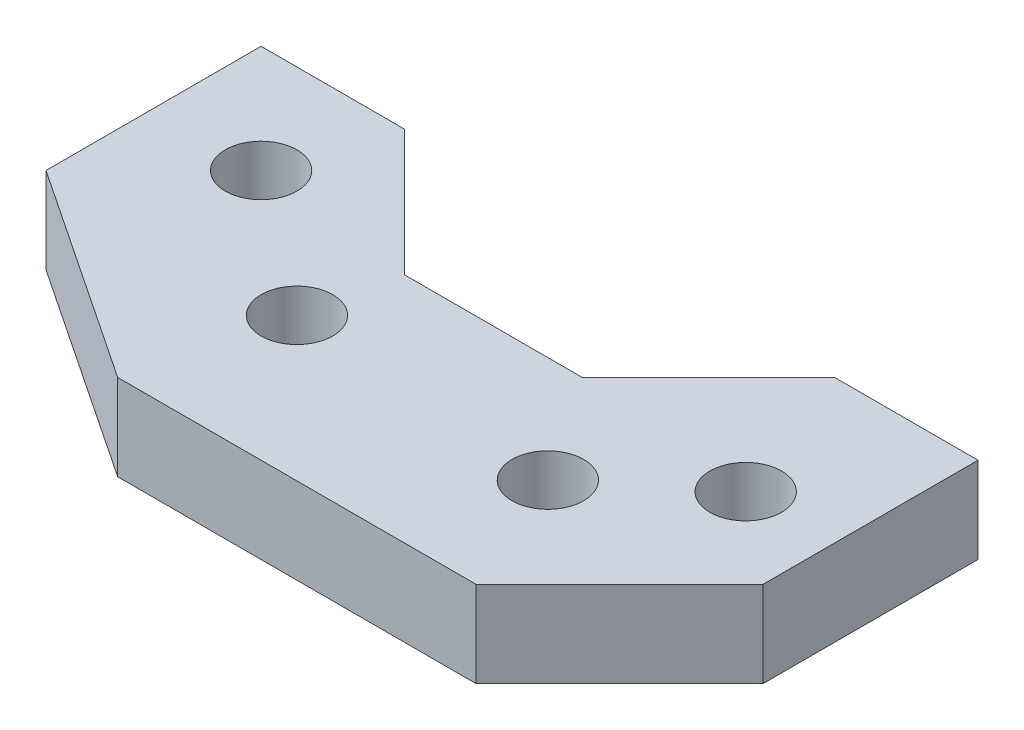
from build123d import *

# Parameters (mm, degrees)
SKETCH1_R           = 6.35
BOSS_EXTRUDE1_DEPTH = 15.24


with BuildPart() as part:
    # Sketch1 → Boss-Extrude1 (new body)
    with BuildSketch(Plane(origin=(0, 0, 0), x_dir=(1, 0, 0), z_dir=(0, 1, 0))):
        Polygon((0, 0), (0, -38.1), (38.1, -63.5), (101.6, -63.5), (127, -38.1), (127, 0), (101.6, 0), (79.248, -22.352), (47.752, -22.352), (25.4, 0), align=None)
        with Locations((19.05, -19.05)):
            Circle(SKETCH1_R, mode=Mode.SUBTRACT)
        with Locations((44.45, -38.1)):
            Circle(SKETCH1_R, mode=Mode.SUBTRACT)
        with Locations((91.948, -41.148)):
            Circle(SKETCH1_R, mode=Mode.SUBTRACT)
        with Locations((111.252, -25.4)):
            Circle(SKETCH1_R, mode=Mode.SUBTRACT)
    extrude(amount=BOSS_EXTRUDE1_DEPTH)


solid = part.part
